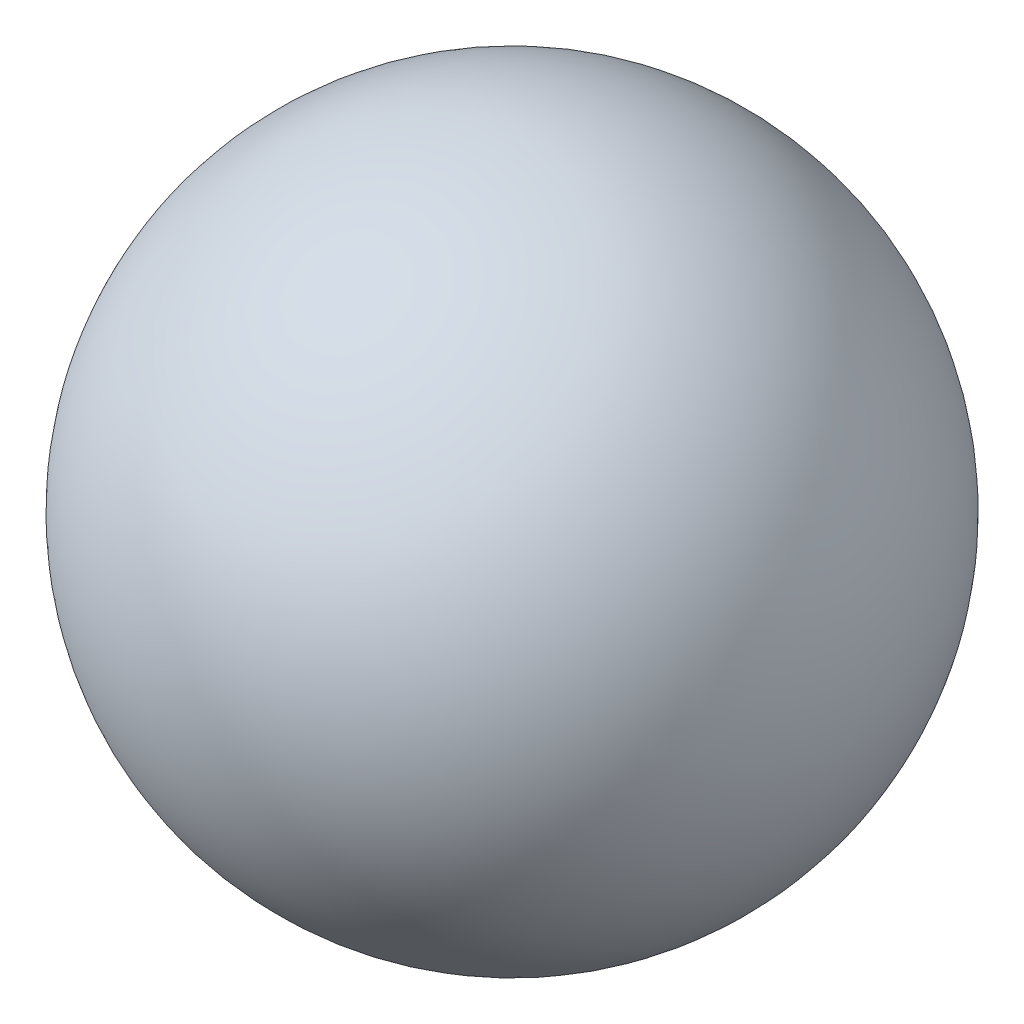
from build123d import *


with BuildPart() as part:
    # RevolveS → Revolve 2 (revolve)
    with BuildSketch(Plane.XY):
        with BuildLine():
            Line((0.5, 0), (-0.5, 0))
            ThreePointArc((-0.5, 0), (0, 0.5), (0.5, 0))
        make_face()
    revolve(axis=Axis((0.5, 0, 0), (-1, 0, 0)))


solid = part.part
